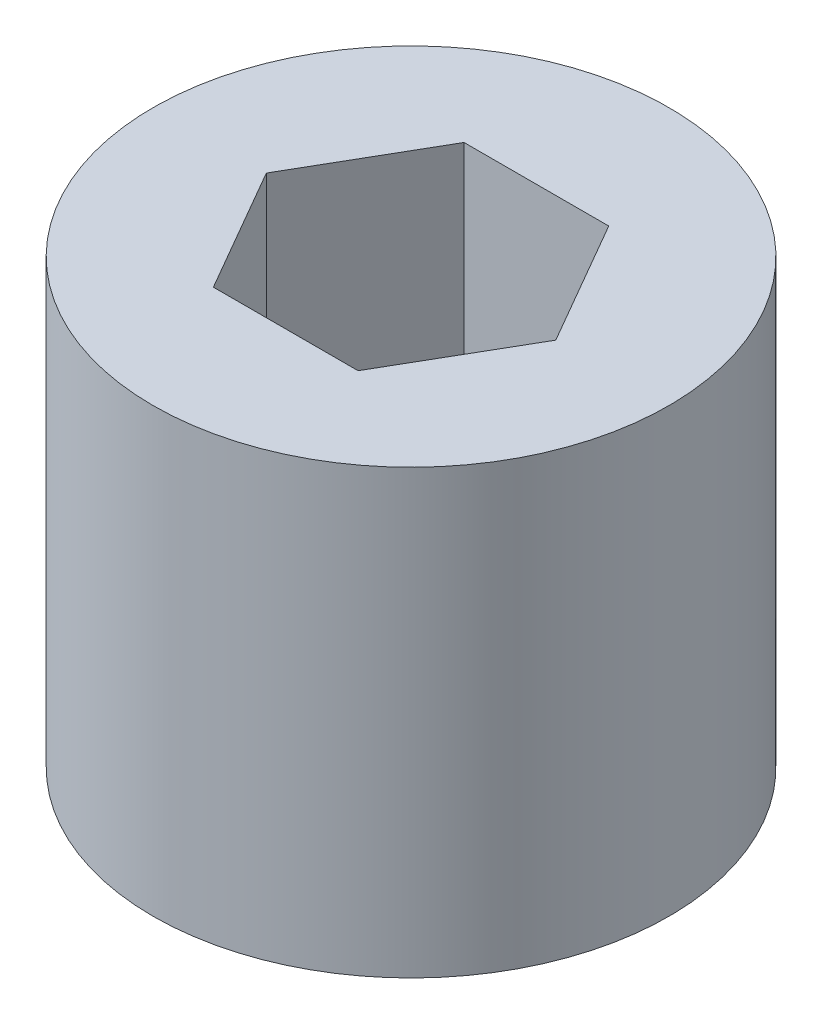
from build123d import *

# Parameters (mm, degrees)
SKETCH1_R           = 8.75
BOSS_EXTRUDE1_DEPTH = 15


with BuildPart() as part:
    # Sketch1 → Boss-Extrude1 (new body)
    with BuildSketch(Plane(origin=(0, 0, 0), x_dir=(1, 0, 0), z_dir=(0, 1, 0))):
        Circle(SKETCH1_R)
        Polygon((4.907477288, 0), (2.453738644, 4.25), (-2.453738644, 4.25), (-4.907477288, 0), (-2.453738644, -4.25), (2.453738644, -4.25), align=None, mode=Mode.SUBTRACT)
    extrude(amount=BOSS_EXTRUDE1_DEPTH)


solid = part.part
